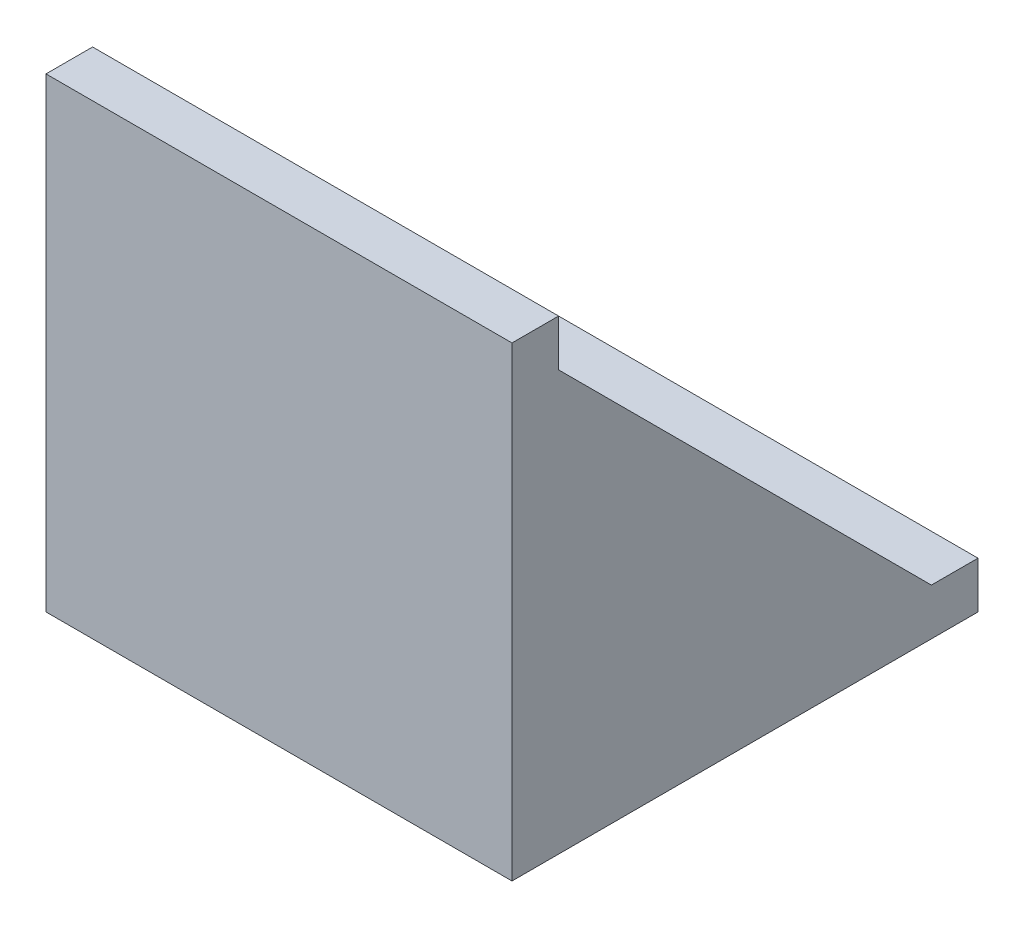
from build123d import *

# Parameters (mm, degrees)
EXTRUDE_1_DEPTH     = 20
CUT_EXTRUDE_START   = -2
SKETCH_3_W          = 18
SKETCH_3_H          = 16
CUT_EXTRUDE_1_DEPTH = 16


with BuildPart() as part:
    # 草图1 → 凸台-拉伸1 (new body)
    with BuildSketch(Plane(origin=(0, 0, 0), x_dir=(0, 0, -1), z_dir=(1, 0, 0))):
        Polygon((-6.026925143, -0.344583577), (-26.026925143, -0.344583577), (-26.026925143, 19.655416423), (-24.026925143, 19.655416423), (-24.026925143, 17.655416423), (-8.026925143, 1.655416423), (-6.026925143, 1.655416423), align=None)
    extrude(amount=EXTRUDE_1_DEPTH)

    # 草图3 → 切除-拉伸1 (cut)
    with BuildSketch(Plane.XZ.offset(0.344583577).offset(CUT_EXTRUDE_START)):
        with Locations((10, 16.026925143)):
            Rectangle(SKETCH_3_W, SKETCH_3_H)
    extrude(amount=-CUT_EXTRUDE_1_DEPTH, mode=Mode.SUBTRACT)


solid = part.part
